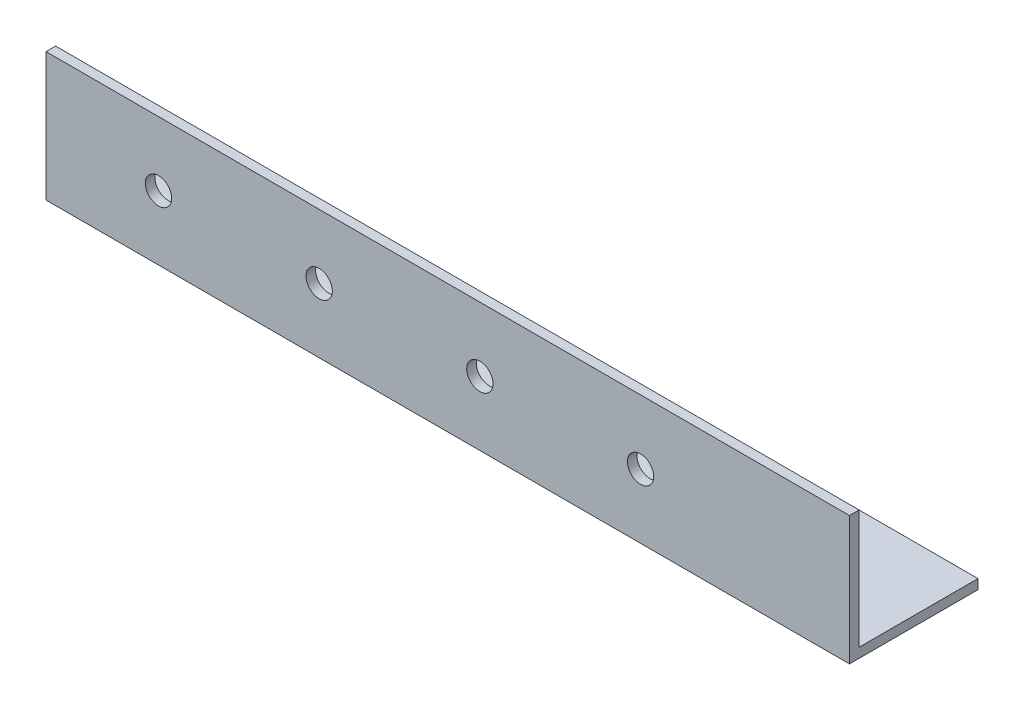
from build123d import *

# Parameters (mm, degrees)
EXTRUDE_1_DEPTH     = 250
SKETCH_2_R          = 4.1
CUT_EXTRUDE_1_DEPTH = 10


with BuildPart() as part:
    # Эскиз1 → Вытянуть-Тонкостенный1 (new body)
    with BuildSketch(Plane(origin=(0, 0, 0), x_dir=(0, 0, -1), z_dir=(1, 0, 0))):
        Polygon((40, 0), (0, 0), (0, 40), (3, 40), (3, 3), (40, 3), align=None)
    extrude(amount=EXTRUDE_1_DEPTH)

    # Эскиз2 → Вырез-Вытянуть1 (cut)
    with BuildSketch(Plane.XY):
        with Locations((35, 20)):
            Circle(SKETCH_2_R)
        with Locations((85, 20)):
            Circle(SKETCH_2_R)
        with Locations((135, 20)):
            Circle(SKETCH_2_R)
        with Locations((185, 20)):
            Circle(SKETCH_2_R)
    extrude(amount=-CUT_EXTRUDE_1_DEPTH, mode=Mode.SUBTRACT)


solid = part.part
